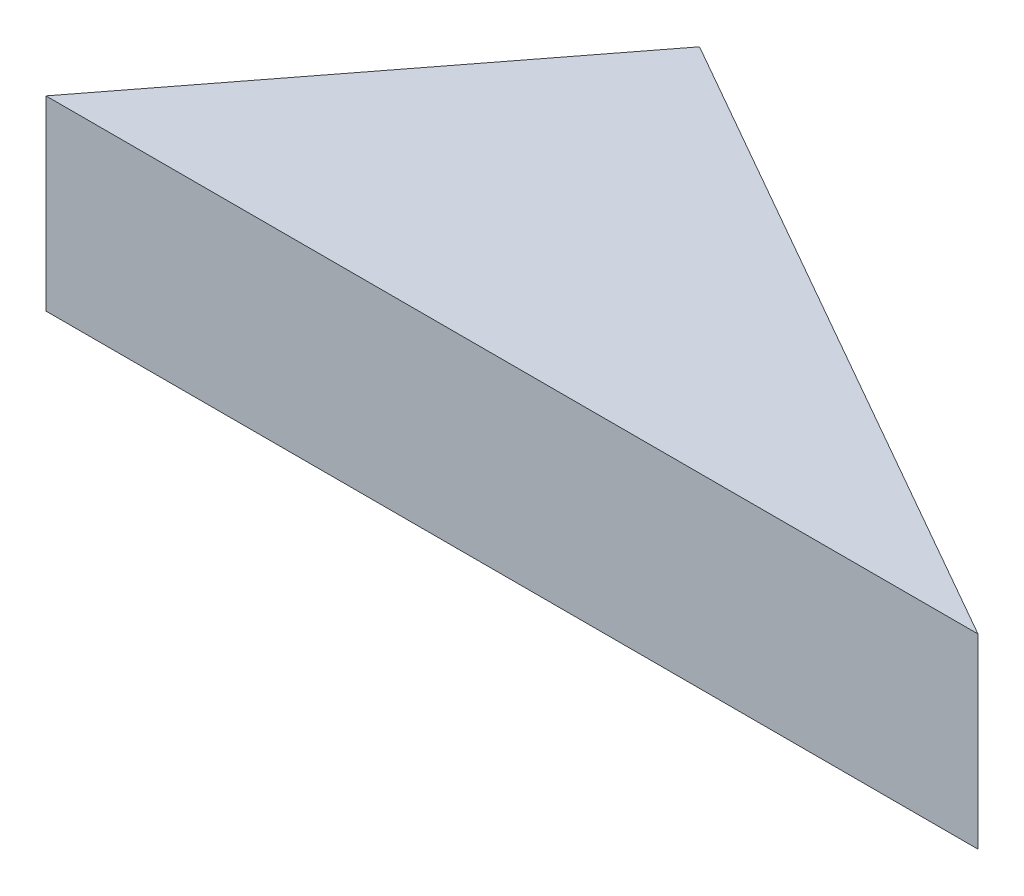
from build123d import *

# Parameters (mm, degrees)
BOSS_EXTRUDE1_DEPTH = 1


with BuildPart() as part:
    # Sketch2 → Boss-Extrude1 (new body)
    with BuildSketch(Plane(origin=(0, 0, 0), x_dir=(1, 0, 0), z_dir=(0, 1, 0))):
        Polygon((0, 0), (5, 0), (1.525, 1.981003534), align=None)
    extrude(amount=BOSS_EXTRUDE1_DEPTH)


solid = part.part
